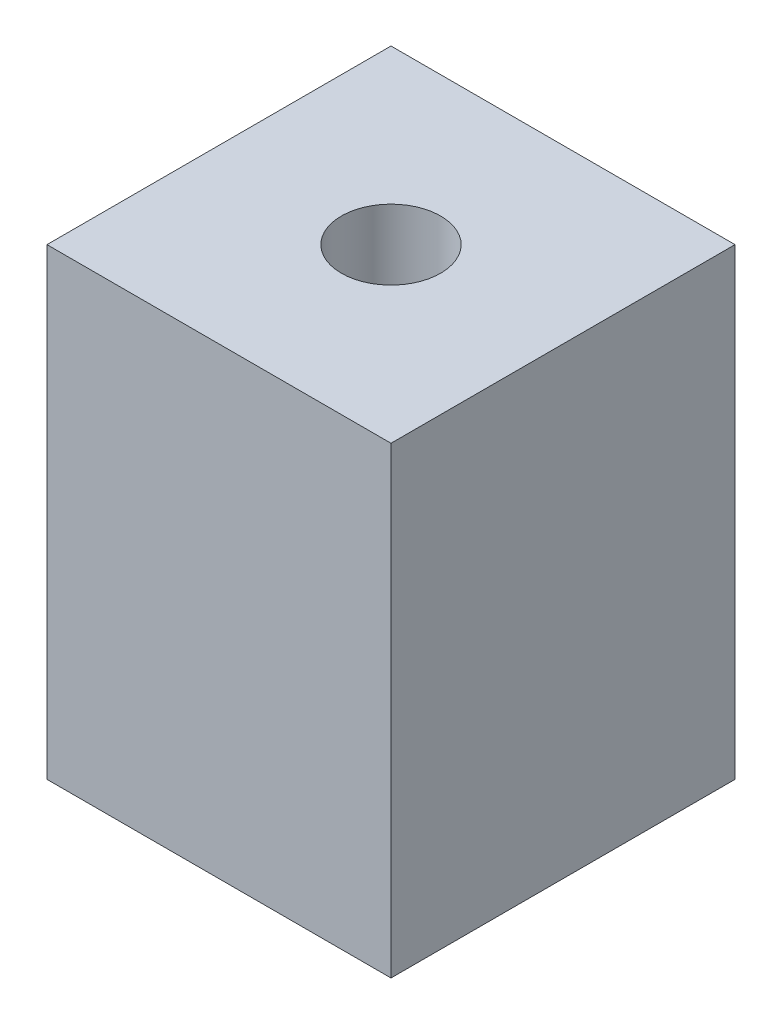
from build123d import *

# Parameters (mm, degrees)
SKETCH2_W                  = 2.6
SKETCH2_H                  = 2.6
BOSS_EXTRUDE1_DEPTH        = 3.5
M1X0_25_TAPPED_HOLE1_D     = 0.75
M1X0_25_TAPPED_HOLE1_DEPTH = 2.5
M1X0_25_TAPPED_HOLE1_TIP   = 0.225322732


with BuildPart() as part:
    # Sketch2 → Boss-Extrude1 (new body)
    with BuildSketch(Plane(origin=(0, 0, 0), x_dir=(1, 0, 0), z_dir=(0, 1, 0))):
        Rectangle(SKETCH2_W, SKETCH2_H)
    extrude(amount=BOSS_EXTRUDE1_DEPTH)

    # M1x0.25 Tapped Hole1
    with Locations(Plane(origin=(0, 3.5, 0), x_dir=(1, 0, 0), z_dir=(0, 1, 0))):
        with Locations((0, 0)):
            Hole(M1X0_25_TAPPED_HOLE1_D / 2, depth=M1X0_25_TAPPED_HOLE1_DEPTH)
            with Locations((0, 0, -(M1X0_25_TAPPED_HOLE1_DEPTH + M1X0_25_TAPPED_HOLE1_TIP / 2))):  # 118° drill point
                Cone(0, M1X0_25_TAPPED_HOLE1_D / 2, M1X0_25_TAPPED_HOLE1_TIP, mode=Mode.SUBTRACT)


solid = part.part
